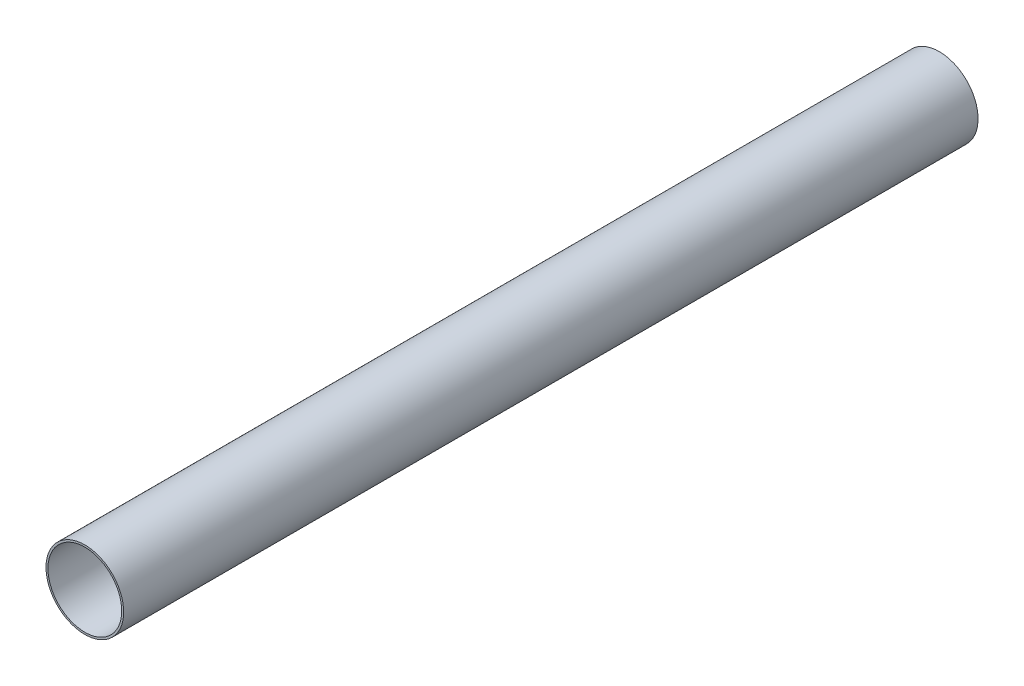
from build123d import *

# Parameters (mm, degrees)
SKETCH_1_W = 0.5
SKETCH_1_H = 220


with BuildPart() as part:
    # 草图1 → 旋转1 (revolve)
    with BuildSketch(Plane.XZ.offset(-70.710678119)):
        with Locations((-60.935678119, 71.9)):
            Rectangle(SKETCH_1_W, SKETCH_1_H)
    revolve(axis=Axis((-70.685678119, 70.710678119, 387.35), (0, 0, -1)))


solid = part.part
